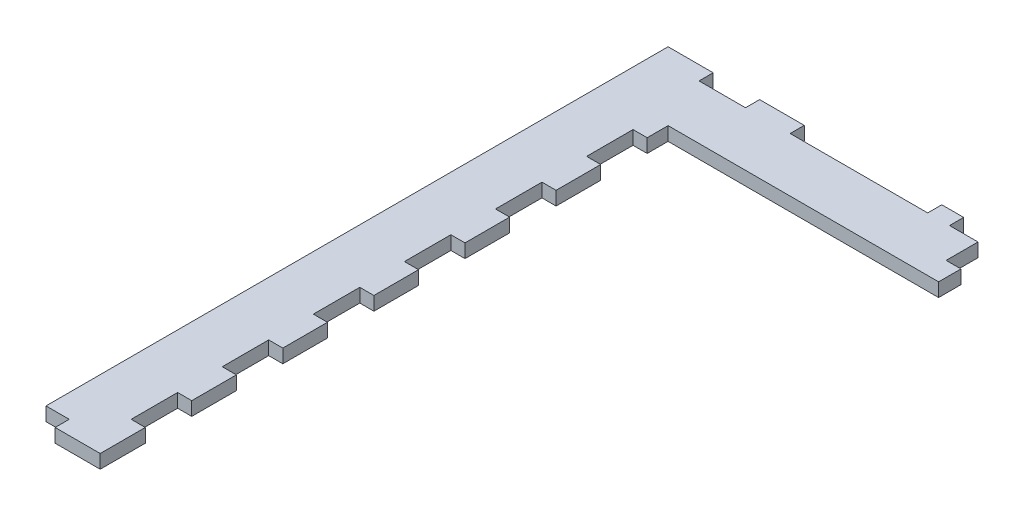
from build123d import *

# Parameters (mm, degrees)
BOSS_EXTRUDE1_DEPTH = 3
SKETCH3_W           = 5.2
SKETCH3_H           = 3.2
SKETCH3_W_2         = 10.2
SKETCH3_W_3         = 30.2
SKETCH3_W_4         = 3.2
SKETCH3_H_2         = 10.2
CUT_EXTRUDE1_DEPTH  = 4


with BuildPart() as part:
    # Sketch1 → Boss-Extrude1 (new body)
    with BuildSketch(Plane(origin=(0, 0, 0), x_dir=(1, 0, 0), z_dir=(0, 1, 0))):
        Polygon((0, 0), (75, 0), (75, -15), (15, -15), (15, -139.694434203), (0, -139.694434203), align=None)
    extrude(amount=-BOSS_EXTRUDE1_DEPTH)

    # Sketch3 → Cut-Extrude1 (cut, through all)
    with BuildSketch(Plane(origin=(0, 0, 0), x_dir=(1, 0, 0), z_dir=(0, 1, 0))):
        with Locations((2.5, -138.194434203)):
            Rectangle(SKETCH3_W, SKETCH3_H)
        with Locations((15, -1.5)):
            Rectangle(SKETCH3_W_2, SKETCH3_H)
        with Locations((45, -1.5)):
            Rectangle(SKETCH3_W_3, SKETCH3_H)
        with Locations((13.5, -104.694434203)):
            Rectangle(SKETCH3_W_4, SKETCH3_H_2)
        with Locations((13.5, -64.694434203)):
            Rectangle(SKETCH3_W_4, SKETCH3_H_2)
        with Locations((13.5, -124.694434203)):
            Rectangle(SKETCH3_W_4, SKETCH3_H_2)
        with Locations((13.5, -44.694434203)):
            Rectangle(SKETCH3_W_4, SKETCH3_H_2)
        with Locations((13.5, -24.694434203)):
            Rectangle(SKETCH3_W_4, SKETCH3_H_2)
        with Locations((13.5, -84.694434203)):
            Rectangle(SKETCH3_W_4, SKETCH3_H_2)
        Polygon((75.1, 0.1), (64.9, 0.1), (64.9, -3.1), (71.15, -3.1), (71.15, -10.1), (74.4, -10.1), (74.4, -15.1), (75.1, -15.1), align=None)
    extrude(amount=-CUT_EXTRUDE1_DEPTH, mode=Mode.SUBTRACT)


solid = part.part
